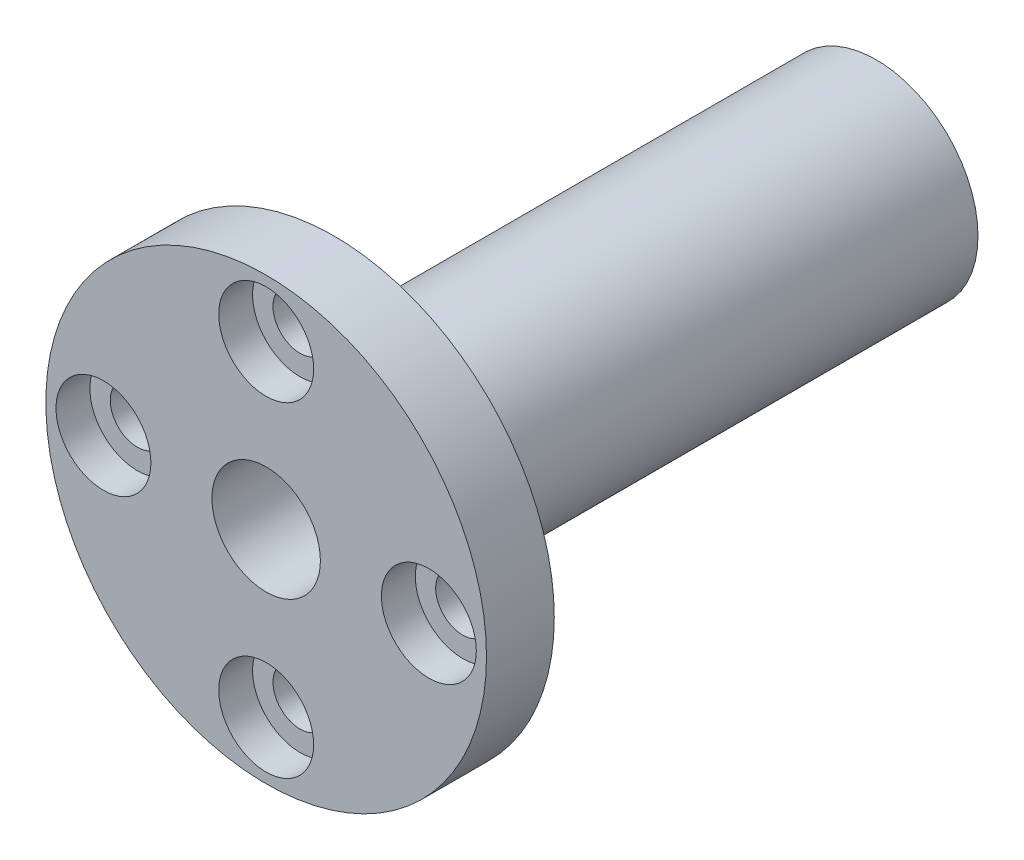
from build123d import *

# Parameters (mm, degrees)
SKETCH1_R           = 16.25
BOSS_EXTRUDE1_DEPTH = 5
SKETCH2_R           = 3.5
CUT_EXTRUDE1_DEPTH  = 2.5
SKETCH3_R           = 7.5
BOSS_EXTRUDE2_DEPTH = 40
SKETCH4_R           = 4
CUT_EXTRUDE2_DEPTH  = 46
SKETCH5_R           = 2
CUT_EXTRUDE3_DEPTH  = 43.5


with BuildPart() as part:
    # Sketch1 → Boss-Extrude1 (new body)
    with BuildSketch(Plane.XY):
        Circle(SKETCH1_R)
    extrude(amount=BOSS_EXTRUDE1_DEPTH)

    # Sketch2 → Cut-Extrude1 (cut)
    with BuildSketch(Plane.XY.offset(5)):
        with Locations((0, 12)):
            Circle(SKETCH2_R)
        with Locations((12, 0)):
            Circle(SKETCH2_R)
        with Locations((0, -12)):
            Circle(SKETCH2_R)
        with Locations((-12, 0)):
            Circle(SKETCH2_R)
    extrude(amount=-CUT_EXTRUDE1_DEPTH, mode=Mode.SUBTRACT)

    # Sketch3 → Boss-Extrude2 (add)
    with BuildSketch(Plane(origin=(0, 0, 0), x_dir=(-1, 0, 0), z_dir=(0, 0, -1))):
        Circle(SKETCH3_R)
    extrude(amount=BOSS_EXTRUDE2_DEPTH)

    # Sketch4 → Cut-Extrude2 (cut, through all)
    with BuildSketch(Plane.XY.offset(5)):
        Circle(SKETCH4_R)
    extrude(amount=-CUT_EXTRUDE2_DEPTH, mode=Mode.SUBTRACT)

    # Sketch5 → Cut-Extrude3 (cut, through all)
    with BuildSketch(Plane.XY.offset(2.5)):
        with Locations((12, 0)):
            Circle(SKETCH5_R)
        with Locations((0, -12)):
            Circle(SKETCH5_R)
        with Locations((-12, 0)):
            Circle(SKETCH5_R)
        with Locations((0, 12)):
            Circle(SKETCH5_R)
    extrude(amount=-CUT_EXTRUDE3_DEPTH, mode=Mode.SUBTRACT)


solid = part.part
